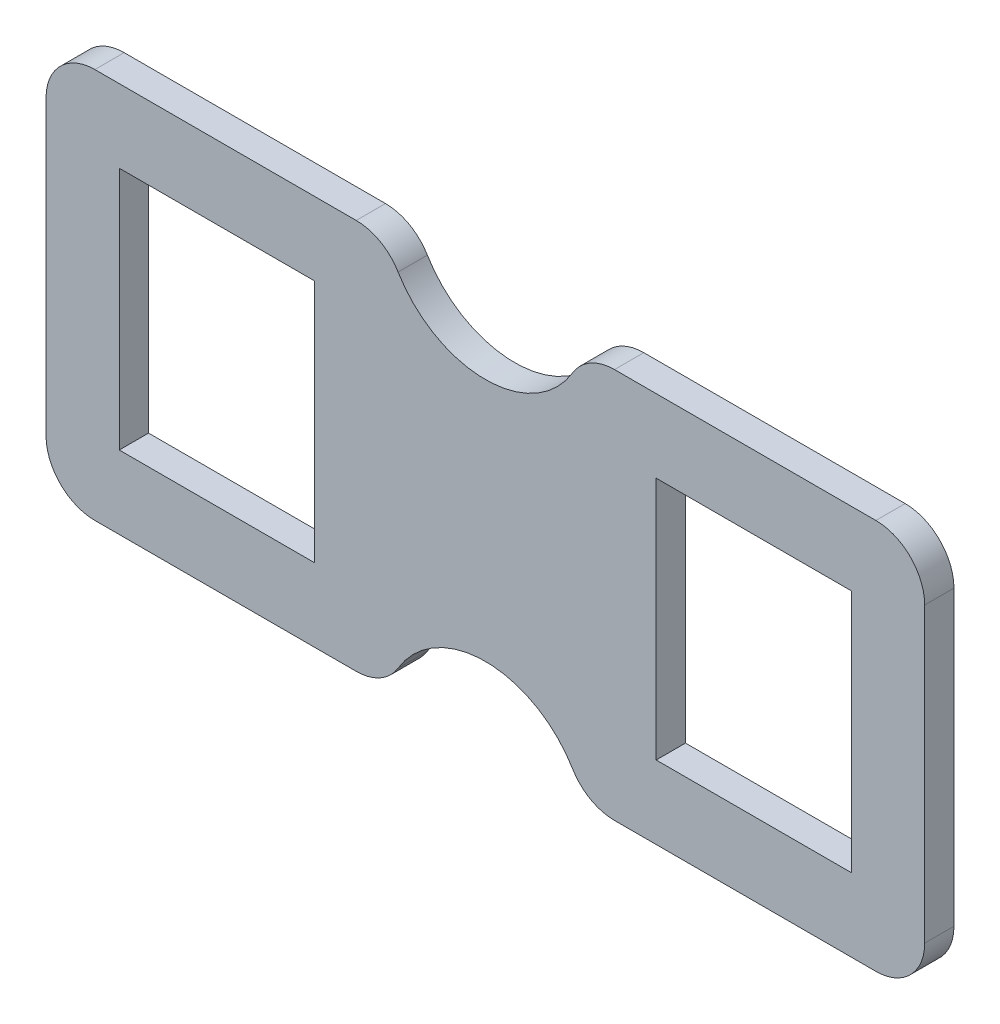
from build123d import *

# Parameters (mm, degrees)
SKETCH1_W           = 50.8
SKETCH1_H           = 63.5
BOSS_EXTRUDE1_DEPTH = 7.62
FILLET1_R           = 12.7


with BuildPart() as part:
    # Sketch1 → Boss-Extrude1 (new body)
    with BuildSketch(Plane.XY):
        with BuildLine():
            Line((0, 0), (-88.9, 0))
            ThreePointArc((-88.9, 0), (-114.3, 19.05), (-139.7, 0))
            Line((-139.7, 0), (-228.6, 0))
            Line((-228.6, 0), (-228.6, 101.6))
            Line((-228.6, 101.6), (-139.7, 101.6))
            ThreePointArc((-139.7, 101.6), (-114.3, 82.55), (-88.9, 101.6))
            Line((-88.9, 101.6), (0, 101.6))
            Line((0, 101.6), (0, 0))
        make_face()
        with Locations((-184.15, 50.8)):
            Rectangle(SKETCH1_W, SKETCH1_H, mode=Mode.SUBTRACT)
        with Locations((-44.45, 50.8)):
            Rectangle(SKETCH1_W, SKETCH1_H, mode=Mode.SUBTRACT)
    extrude(amount=BOSS_EXTRUDE1_DEPTH)

    # Fillet1
    fillet1_edges = [part.edges().sort_by_distance(p)[0] for p in [
        (0, 0, 3.81),
        (-88.9, 0, 3.81),
        (-139.7, 0, 3.81),
        (-228.6, 0, 3.81),
        (-228.6, 101.6, 3.81),
        (-139.7, 101.6, 3.81),
        (-88.9, 101.6, 3.81),
        (0, 101.6, 3.81),
    ]]
    fillet(fillet1_edges, radius=FILLET1_R)


solid = part.part
